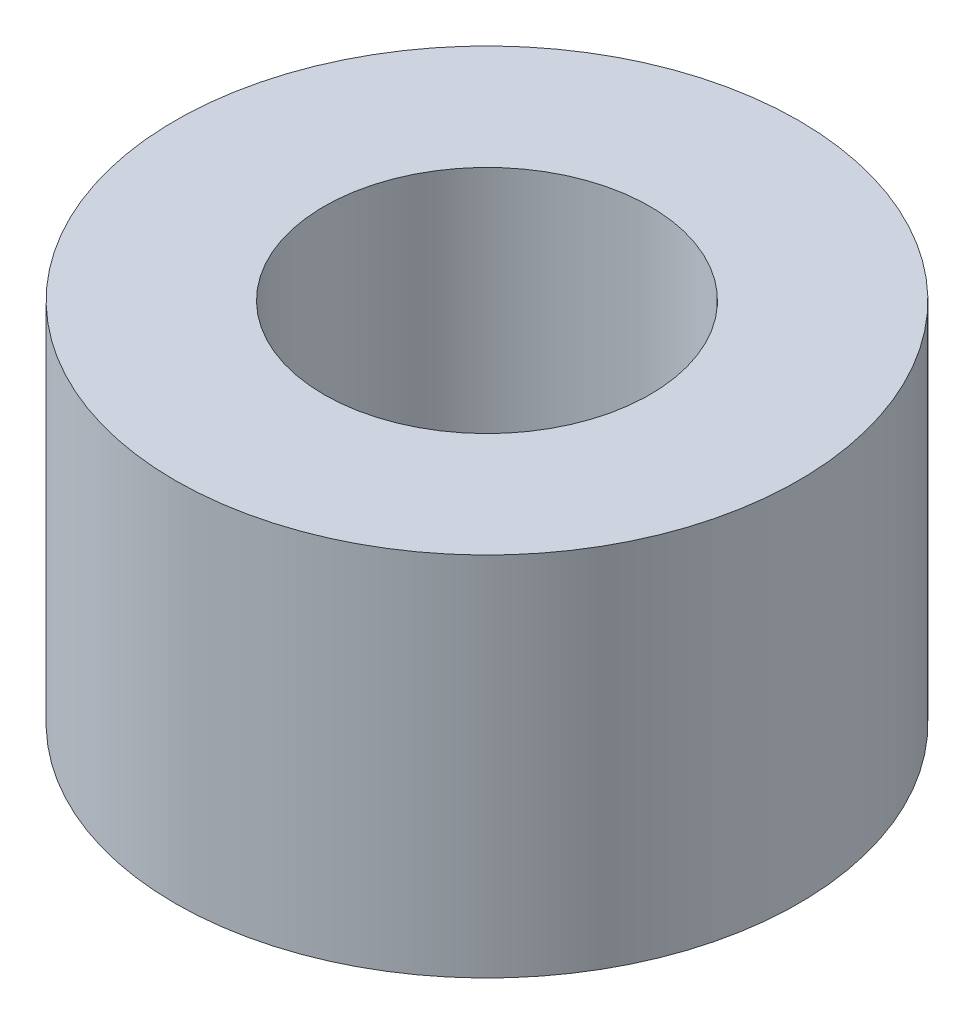
from build123d import *

# Parameters (mm, degrees)
SZKIC1_R                    = 4.255
SZKIC1_R_2                  = 2.225
DODANIE_WYCI_GNI_CIE1_DEPTH = 5


with BuildPart() as part:
    # Szkic1 → Dodanie-wyciągnięcie1 (new body)
    with BuildSketch(Plane(origin=(0, 0, 0), x_dir=(1, 0, 0), z_dir=(0, 1, 0))):
        Circle(SZKIC1_R)
        Circle(SZKIC1_R_2, mode=Mode.SUBTRACT)
    extrude(amount=DODANIE_WYCI_GNI_CIE1_DEPTH)


solid = part.part
